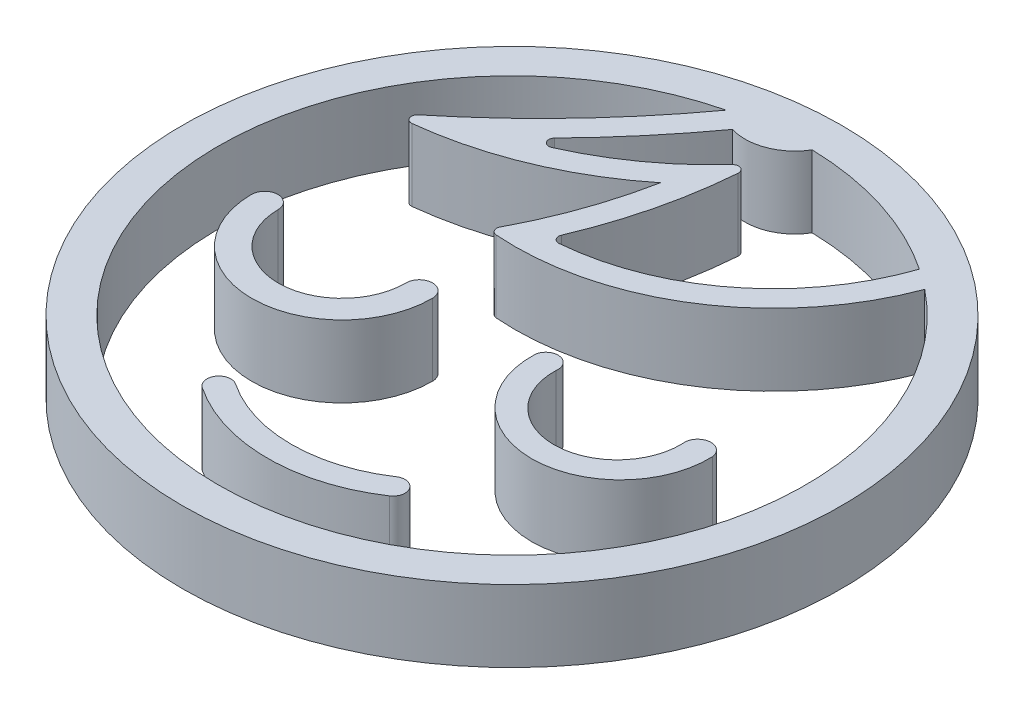
from build123d import *

# Parameters (mm, degrees)
CROQUIS1_R                = 27.5
SALIENTE_EXTRUIR3_DEPTH   = 6
SALIENTE_EXTRUIR3_2_DEPTH = 6
SALIENTE_EXTRUIR3_3_DEPTH = 6
SALIENTE_EXTRUIR3_4_DEPTH = 6


with BuildPart() as part:
    # Croquis1 → Saliente-Extruir3 (new body)
    with BuildSketch(Plane(origin=(0, 0, 0), x_dir=(1, 0, 0), z_dir=(0, 1, 0))):
        Circle(CROQUIS1_R)
        with BuildLine():
            ThreePointArc((-6.481910722, 5.161659186), (6.749911309, 8.499710515), (15.332388636, 19.109365733))
            ThreePointArc((15.332388636, 19.109365733), (-5.261908362, -23.928274497), (-5.901159339, 23.778694633))
            ThreePointArc((-5.901159339, 23.778694633), (-11.725813734, 16.778614453), (-18.406444405, 10.590165925))
            ThreePointArc((-18.406444405, 10.590165925), (-18.552255418, 10.008822773), (-18.035485402, 9.705228534))
            ThreePointArc((-18.035485402, 9.705228534), (-10.284746472, 11.706352258), (-3.398196642, 15.787269012))
            ThreePointArc((-3.398196642, 15.787269012), (-4.77910195, 10.712326415), (-6.886809038, 5.893663462))
            ThreePointArc((-6.886809038, 5.893663462), (-6.882152879, 5.418254788), (-6.481910722, 5.161659186))
        make_face(mode=Mode.SUBTRACT)
        with BuildLine():
            ThreePointArc((0.553855765, 24.493738869), (7.399029371, 23.35603486), (13.650668654, 20.344759652))
            ThreePointArc((13.650668654, 20.344759652), (7.168200526, 11.242778225), (-3.237616322, 7.170010781))
            ThreePointArc((-3.237616322, 7.170010781), (-3.684337904, 7.37498369), (-3.739754637, 7.863351432))
            ThreePointArc((-3.739754637, 7.863351432), (-1.814955726, 13.671675172), (-0.850096282, 19.714068884))
            ThreePointArc((-0.850096282, 19.714068884), (-1.149234355, 20.211325601), (-1.716909146, 20.090938058))
            ThreePointArc((-1.716909146, 20.090938058), (-5.775579982, 16.492523924), (-10.482918218, 13.797647311))
            ThreePointArc((-10.482918218, 13.797647311), (-11.096230859, 13.969574186), (-11.043045611, 14.604304504))
            ThreePointArc((-11.043045611, 14.604304504), (-7.499015993, 18.503713558), (-4.248394951, 22.650881235))
            ThreePointArc((-4.248394951, 22.650881235), (-1.528467266, 22.741552063), (0.553855765, 24.493738869))
        make_face(mode=Mode.SUBTRACT)
    extrude(amount=SALIENTE_EXTRUIR3_DEPTH)


with BuildPart() as body_2:
    # Croquis1 → Saliente-Extruir3 2 (new body)
    with BuildSketch(Plane(origin=(0, 0, 0), x_dir=(1, 0, 0), z_dir=(0, 1, 0))):
        with BuildLine():
            ThreePointArc((5.812888831, -2.127053389), (4.944999806, -0.954199424), (3.772145841, -1.822088449))
            ThreePointArc((3.772145841, -1.822088449), (11.169349937, -9.530541219), (18.566554033, -1.822088449))
            ThreePointArc((18.566554033, -1.822088449), (17.316866775, -0.877366131), (16.372144456, -2.127053389))
            ThreePointArc((16.372144456, -2.127053389), (11.092516644, -7.59016676), (5.812888831, -2.127053389))
        make_face()
    extrude(amount=SALIENTE_EXTRUIR3_2_DEPTH)


with BuildPart() as body_3:
    # Croquis1 → Saliente-Extruir3 3 (new body)
    with BuildSketch(Plane(origin=(0, 0, 0), x_dir=(1, 0, 0), z_dir=(0, 1, 0))):
        with BuildLine():
            ThreePointArc((-17.4051629, -2.121721183), (-18.516794481, -1.020754013), (-19.617761652, -2.132385594))
            ThreePointArc((-19.617761652, -2.132385594), (-12.054197272, -9.623389101), (-4.563193765, -2.059824722))
            ThreePointArc((-4.563193765, -2.059824722), (-5.67481204, -0.958870731), (-6.775766031, -2.070489005))
            ThreePointArc((-6.775766031, -2.070489005), (-12.064848376, -7.410803529), (-17.4051629, -2.121721183))
        make_face()
    extrude(amount=SALIENTE_EXTRUIR3_3_DEPTH)


with BuildPart() as body_4:
    # Croquis1 → Saliente-Extruir3 4 (new body)
    with BuildSketch(Plane(origin=(0, 0, 0), x_dir=(1, 0, 0), z_dir=(0, 1, 0))):
        with BuildLine():
            ThreePointArc((-6.591798022, -16.478913263), (-7.979292605, -16.752516596), (-7.705689271, -18.140011178))
            ThreePointArc((-7.705689271, -18.140011178), (0.114097404, -20.519185991), (7.93388408, -18.140011178))
            ThreePointArc((7.93388408, -18.140011178), (8.207487413, -16.752516596), (6.819992831, -16.478913263))
            ThreePointArc((6.819992831, -16.478913263), (0.114097404, -18.519185991), (-6.591798022, -16.478913263))
        make_face()
    extrude(amount=SALIENTE_EXTRUIR3_4_DEPTH)


solid = Compound([part.part, body_2.part, body_3.part, body_4.part])
